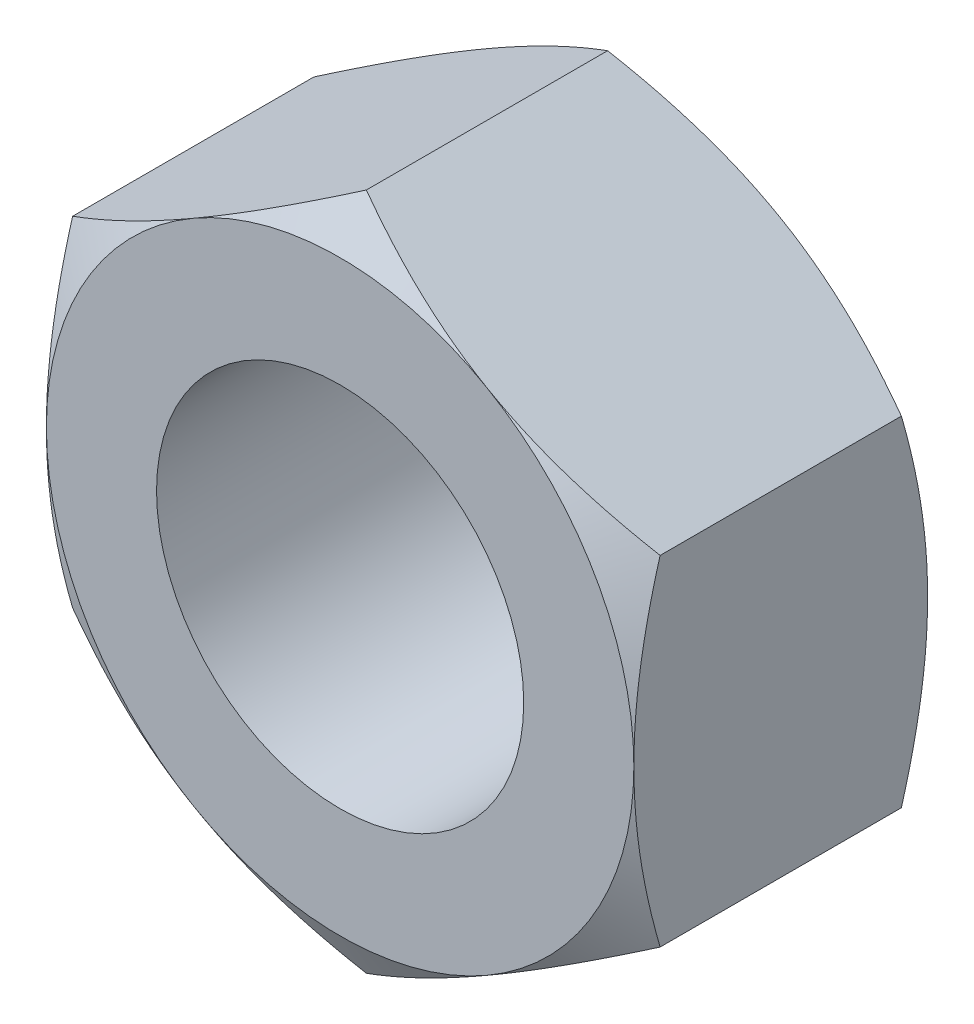
from build123d import *

# Parameters (mm, degrees)
SKETCH1_R           = 1.25
BOSS_EXTRUDE1_DEPTH = 2
SKETCH2_OUTSIDE_W   = 14.214
SKETCH2_OUTSIDE_H   = 14.832
SKETCH2_OUTSIDE_R   = 2
CUT_EXTRUDE1_DEPTH  = 2
CUT_EXTRUDE1_TAPER  = 60
SKETCH3_OUTSIDE_W   = 14.214
SKETCH3_OUTSIDE_H   = 14.832
SKETCH3_OUTSIDE_R   = 2
CUT_EXTRUDE2_DEPTH  = 2
CUT_EXTRUDE2_TAPER  = 60


with BuildPart() as part:
    # Sketch1 → Boss-Extrude1 (new body)
    with BuildSketch(Plane.XY):
        Polygon((0, -2.309401077), (2, -1.154700538), (2, 1.154700538), (0, 2.309401077), (-2, 1.154700538), (-2, -1.154700538), align=None)
        Circle(SKETCH1_R, mode=Mode.SUBTRACT)
    extrude(amount=BOSS_EXTRUDE1_DEPTH)

    # Sketch2 outside → Cut-Extrude1 (cut)
    with BuildSketch(Plane.XY.offset(2)):
        Rectangle(SKETCH2_OUTSIDE_W, SKETCH2_OUTSIDE_H)
        Circle(SKETCH2_OUTSIDE_R, mode=Mode.SUBTRACT)
    extrude(amount=-CUT_EXTRUDE1_DEPTH, taper=CUT_EXTRUDE1_TAPER, mode=Mode.SUBTRACT)

    # Sketch3 outside → Cut-Extrude2 (cut)
    with BuildSketch(Plane(origin=(0, 0, 0), x_dir=(-1, 0, 0), z_dir=(0, 0, -1))):
        Rectangle(SKETCH3_OUTSIDE_W, SKETCH3_OUTSIDE_H)
        Circle(SKETCH3_OUTSIDE_R, mode=Mode.SUBTRACT)
    extrude(amount=-CUT_EXTRUDE2_DEPTH, taper=CUT_EXTRUDE2_TAPER, mode=Mode.SUBTRACT)


solid = part.part
